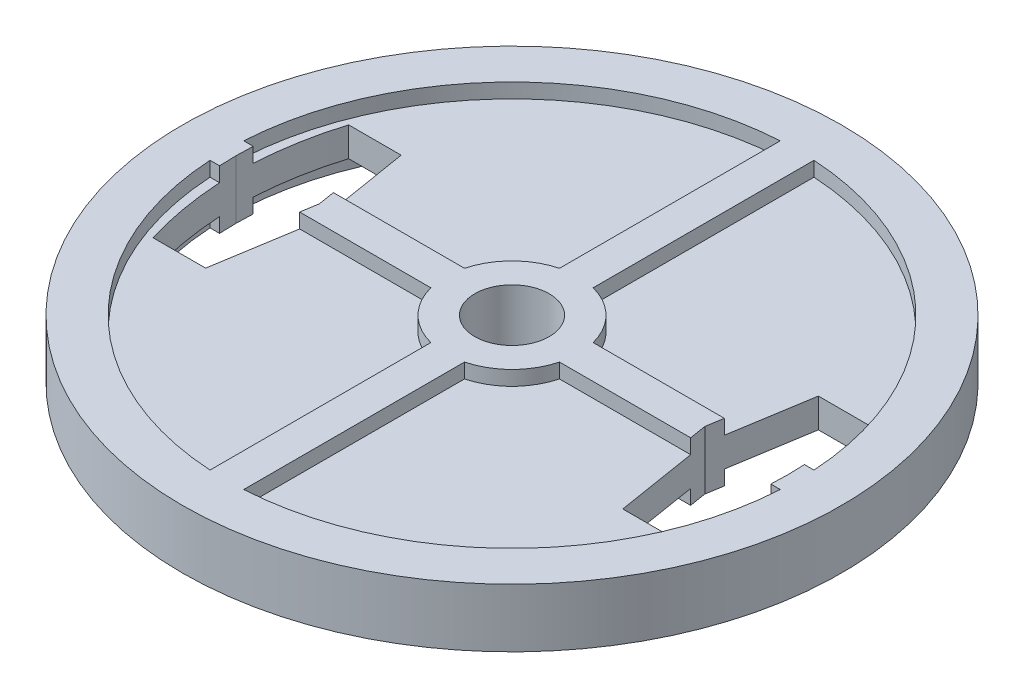
from build123d import *

# Parameters (mm, degrees)
SKETCH1_R               = 225
SKETCH1_R_2             = 25.4
BOSS_EXTRUDE1_DEPTH     = 20
CUT_EXTRUDE1_DEPTH      = 21
CUT_EXTRUDE1_DEPTH_BACK = 1
CUT_EXTRUDE2_START      = 20
CUT_EXTRUDE2_DEPTH      = 10


with BuildPart() as part:
    # Sketch1 → Boss-Extrude1 (new body)
    with BuildSketch(Plane(origin=(0, 0, 0), x_dir=(1, 0, 0), z_dir=(0, 1, 0))):
        Circle(SKETCH1_R)
        Circle(SKETCH1_R_2, mode=Mode.SUBTRACT)
    extrude(amount=BOSS_EXTRUDE1_DEPTH)

    # Sketch2 → Cut-Extrude1 (cut, two sides)
    with BuildSketch(Plane(origin=(0, 0, 0), x_dir=(1, 0, 0), z_dir=(0, 1, 0))) as cut_extrude1_sk:
        with BuildLine():
            Line((-178.258542487, 66.764776795), (-142.42023427, 66.764776795))
            Line((-142.42023427, 66.764776795), (-131.611855601, 0))
            Line((-131.611855601, 0), (-142.42023427, -66.764776795))
            Line((-142.42023427, -66.764776795), (-178.258542487, -66.764776795))
            add(Edge.make_bspline(
                [(-188.498059121, 0), (-188.498059121, -23.199214205), (-184.204279862, -48.203238876), (-178.258542487, -66.764776795)],
                knots=[0, 0, 0, 0, 1, 1, 1, 1], degree=3))
            add(Edge.make_bspline(
                [(-188.498059121, 0), (-188.498059121, 23.199214205), (-184.204279862, 48.203238876), (-178.258542487, 66.764776795)],
                knots=[0, 0, 0, 0, 1, 1, 1, 1], degree=3))
        make_face()
        with BuildLine():
            Line((178.258542487, -66.764776795), (142.42023427, -66.764776795))
            Line((142.42023427, -66.764776795), (131.611855601, 0))
            Line((131.611855601, 0), (142.42023427, 66.764776795))
            Line((142.42023427, 66.764776795), (178.258542487, 66.764776795))
            add(Edge.make_bspline(
                [(188.498059121, 0), (188.498059121, 23.199214205), (184.204279862, 48.203238876), (178.258542487, 66.764776795)],
                knots=[0, 0, 0, 0, 1, 1, 1, 1], degree=3))
            add(Edge.make_bspline(
                [(188.498059121, 0), (188.498059121, -23.199214205), (184.204279862, -48.203238876), (178.258542487, -66.764776795)],
                knots=[0, 0, 0, 0, 1, 1, 1, 1], degree=3))
        make_face()
    extrude(amount=CUT_EXTRUDE1_DEPTH, mode=Mode.SUBTRACT)
    extrude(cut_extrude1_sk.sketch, amount=-CUT_EXTRUDE1_DEPTH_BACK, mode=Mode.SUBTRACT)

    # Sketch3 → Cut-Extrude2 (cut)
    with BuildSketch(Plane(origin=(0, 0, 0), x_dir=(1, 0, 0), z_dir=(0, 1, 0)).offset(CUT_EXTRUDE2_START)):
        with BuildLine():
            Line((-11.5, 43.919357919), (-11.5, 194.660602074))
            ThreePointArc((-11.5, 194.660602074), (-137.885822331, 137.885822331), (-194.660602074, 11.5))
            Line((-194.660602074, 11.5), (-43.919357919, 11.5))
            ThreePointArc((-43.919357919, 11.5), (-32.102647866, 32.102647866), (-11.5, 43.919357919))
        make_face()
        with BuildLine():
            Line((11.5, 43.919357919), (11.5, 194.660602074))
            ThreePointArc((11.5, 194.660602074), (137.885822331, 137.885822331), (194.660602074, 11.5))
            Line((194.660602074, 11.5), (43.919357919, 11.5))
            ThreePointArc((43.919357919, 11.5), (32.102647866, 32.102647866), (11.5, 43.919357919))
        make_face()
        with BuildLine():
            Line((43.919357919, -11.5), (194.660602074, -11.5))
            ThreePointArc((194.660602074, -11.5), (137.885822331, -137.885822331), (11.5, -194.660602074))
            Line((11.5, -194.660602074), (11.5, -43.919357919))
            ThreePointArc((11.5, -43.919357919), (32.102647866, -32.102647866), (43.919357919, -11.5))
        make_face()
        with BuildLine():
            Line((-11.5, -43.919357919), (-11.5, -194.660602074))
            ThreePointArc((-11.5, -194.660602074), (-137.885822331, -137.885822331), (-194.660602074, -11.5))
            Line((-194.660602074, -11.5), (-43.919357919, -11.5))
            ThreePointArc((-43.919357919, -11.5), (-32.102647866, -32.102647866), (-11.5, -43.919357919))
        make_face()
    extrude(amount=-CUT_EXTRUDE2_DEPTH, mode=Mode.SUBTRACT)

    # Mirror2: part across plane


with BuildPart() as part_1:
    add(part.part)
    add(part.part.mirror(Plane.ZX))


solid = part_1.part
